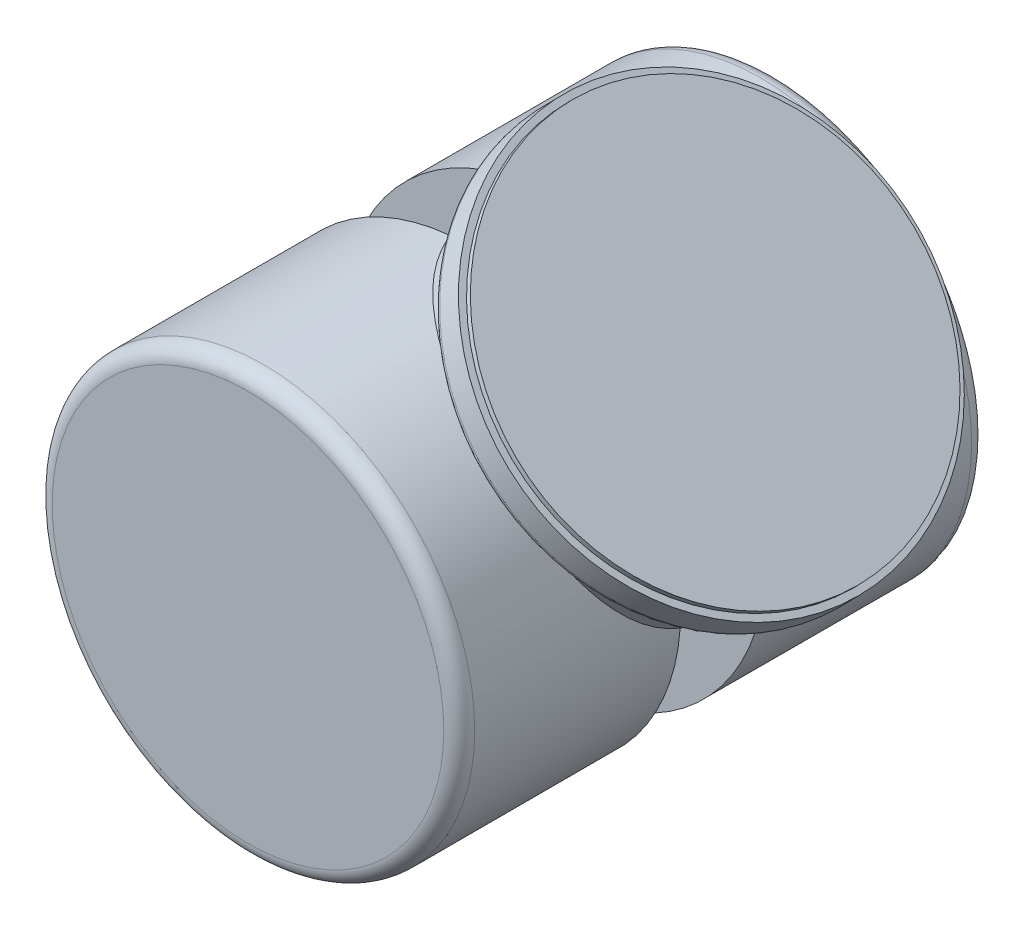
from build123d import *

# Parameters (mm, degrees)
SKETCH2_R           = 34.7138244
BOSS_EXTRUDE1_DEPTH = 43.3659661
FILLET1_R           = 2.54
SKETCH4_R           = 34.7138244
CUT_EXTRUDE1_DEPTH  = 6.985
SCALE1_SCALE        = 2.1025641


with BuildPart() as part:
    # Sketch2 → Boss-Extrude1 (new body, symmetric)
    with BuildSketch(Plane.XY):
        with Locations((-4.885886043, 8.460037767)):
            Circle(SKETCH2_R)
    extrude(amount=BOSS_EXTRUDE1_DEPTH, both=True)

    # Sketch3 → Revolve1 (revolve)
    with BuildSketch(Plane.XY):
        with BuildLine():
            Line((22.617188767, -2.954559536), (39.991940689, 15.756711766))
            ThreePointArc((39.991940689, 15.756711766), (40.875583615, 16.161668708), (41.78676132, 15.823186604))
            Line((41.78676132, 15.823186604), (42.898157249, 14.791176098))
            Line((42.898157249, 14.791176098), (48.074161234, 14.791176098))
            ThreePointArc((48.074161234, 14.791176098), (48.566620636, 14.890542194), (48.982018985, 15.173091472))
            Line((48.982018985, 15.173091472), (52.064778569, 18.324488421))
            Line((52.064778569, 18.324488421), (51.292291814, 19.080150428))
            Line((51.292291814, 19.080150428), (51.913951053, 19.715650854))
            Line((51.913951053, 19.715650854), (28.515190783, 42.604786571))
            Line((28.515190783, 42.604786571), (2.85696712, 16.37528486))
            Line((2.85696712, 16.37528486), (22.617188767, -2.954559536))
        make_face()
    revolve(axis=Axis((2.85696712, 16.37528486, 0), (0.699279233, 0.714848623, 0)))

    # Fillet1
    fillet1_edges = [part.edges().sort_by_distance(p)[0] for p in [
        (-39.599710443, 8.460037767, -43.3659661),
        (-39.599710443, 8.460037767, 43.3659661),
    ]]
    fillet(fillet1_edges, radius=FILLET1_R)

    # Sketch4 → Cut-Extrude1 (cut, symmetric)
    with BuildSketch(Plane.XY):
        with Locations((-4.885886043, 8.460037767)):
            Circle(SKETCH4_R)
    extrude(amount=CUT_EXTRUDE1_DEPTH, both=True, mode=Mode.SUBTRACT)


with BuildPart() as part_1:
    # Scale1: scaled about (0, 0, 0)
    add(part.part.scale(SCALE1_SCALE))


solid = part_1.part
